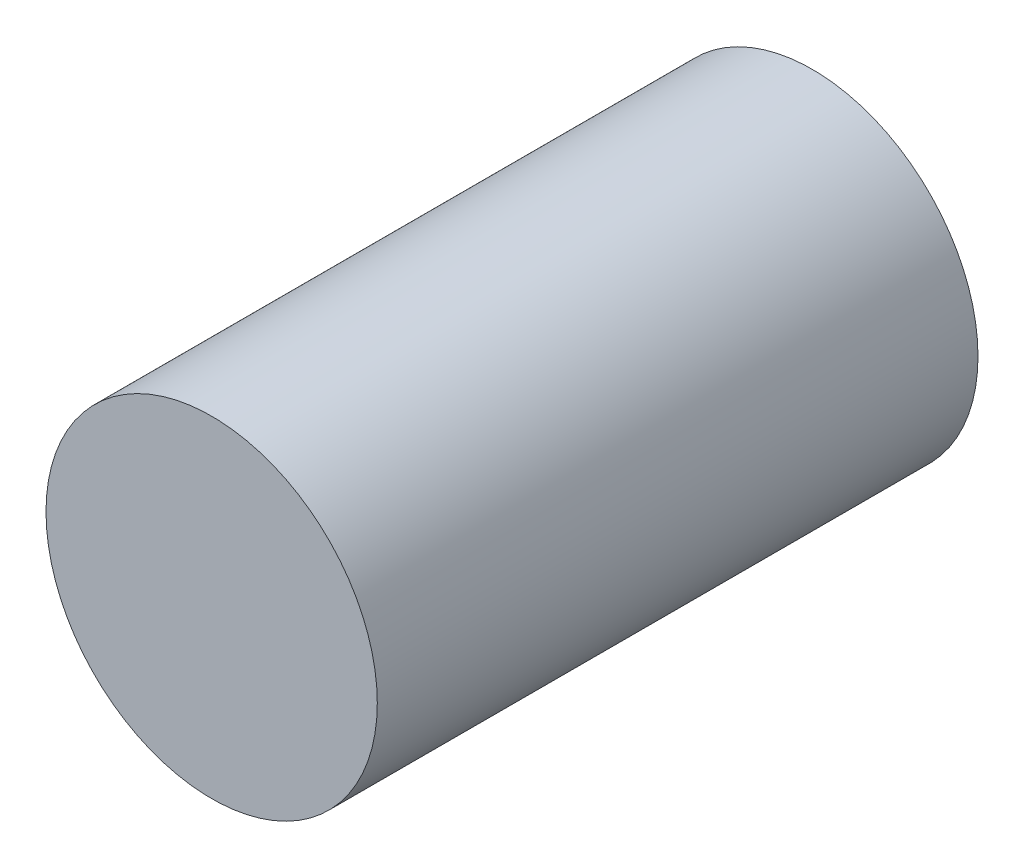
from build123d import *

# Parameters (mm, degrees)
SKETCH1_R           = 4.95
BOSS_EXTRUDE1_DEPTH = 17.95


with BuildPart() as part:
    # Sketch1 → Boss-Extrude1 (new body)
    with BuildSketch(Plane.XY):
        with Locations((-5.17048637, -0.728611751)):
            Circle(SKETCH1_R)
    extrude(amount=BOSS_EXTRUDE1_DEPTH)


solid = part.part
